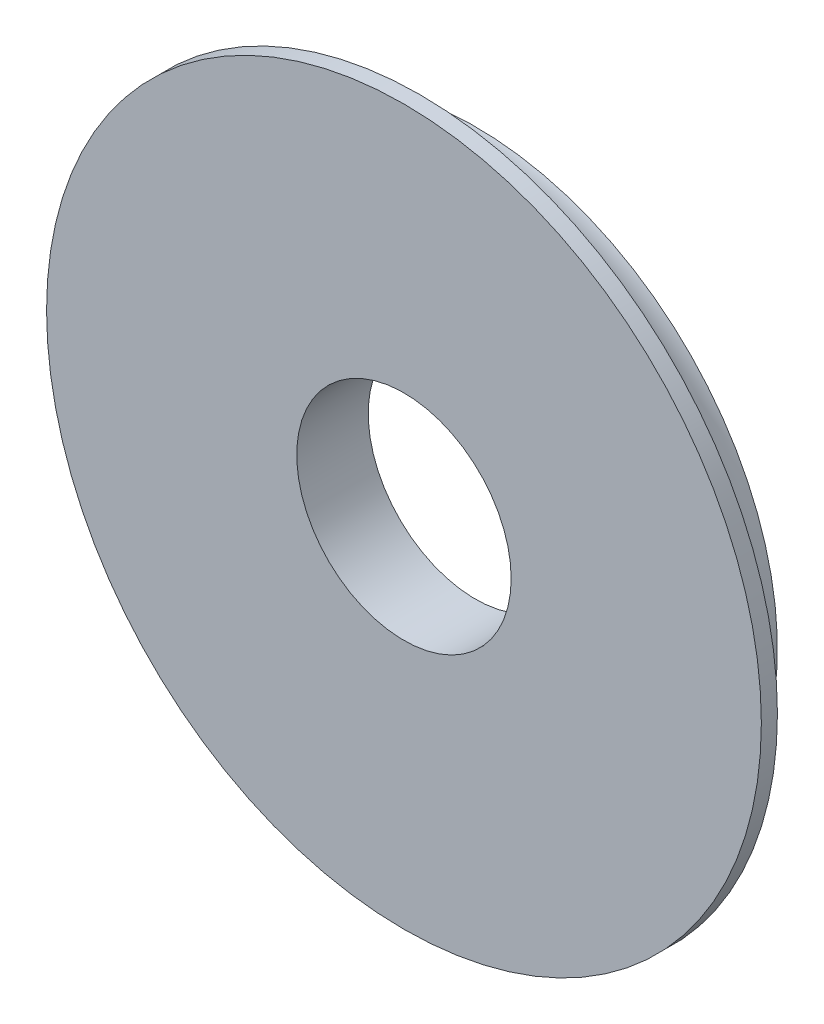
from build123d import *

# Parameters (mm, degrees)
SKETCH1_R           = 10
SKETCH1_R_2         = 3
BOSS_EXTRUDE1_DEPTH = 2
SKETCH2_R           = 1.55


with BuildPart() as part:
    # Sketch1 → Boss-Extrude1 (new body)
    with BuildSketch(Plane.XY):
        Circle(SKETCH1_R)
        Circle(SKETCH1_R_2, mode=Mode.SUBTRACT)
    extrude(amount=BOSS_EXTRUDE1_DEPTH)

    # Sketch2 → Cut-Revolve1 (revolve, cut)
    with BuildSketch(Plane(origin=(0, 0, 0), x_dir=(1, 0, 0), z_dir=(0, 1, 0))):
        with Locations((10, 0)):
            Circle(SKETCH2_R)
    revolve(axis=Axis((0, 0, 2), (0, 0, -1)), mode=Mode.SUBTRACT)


solid = part.part
